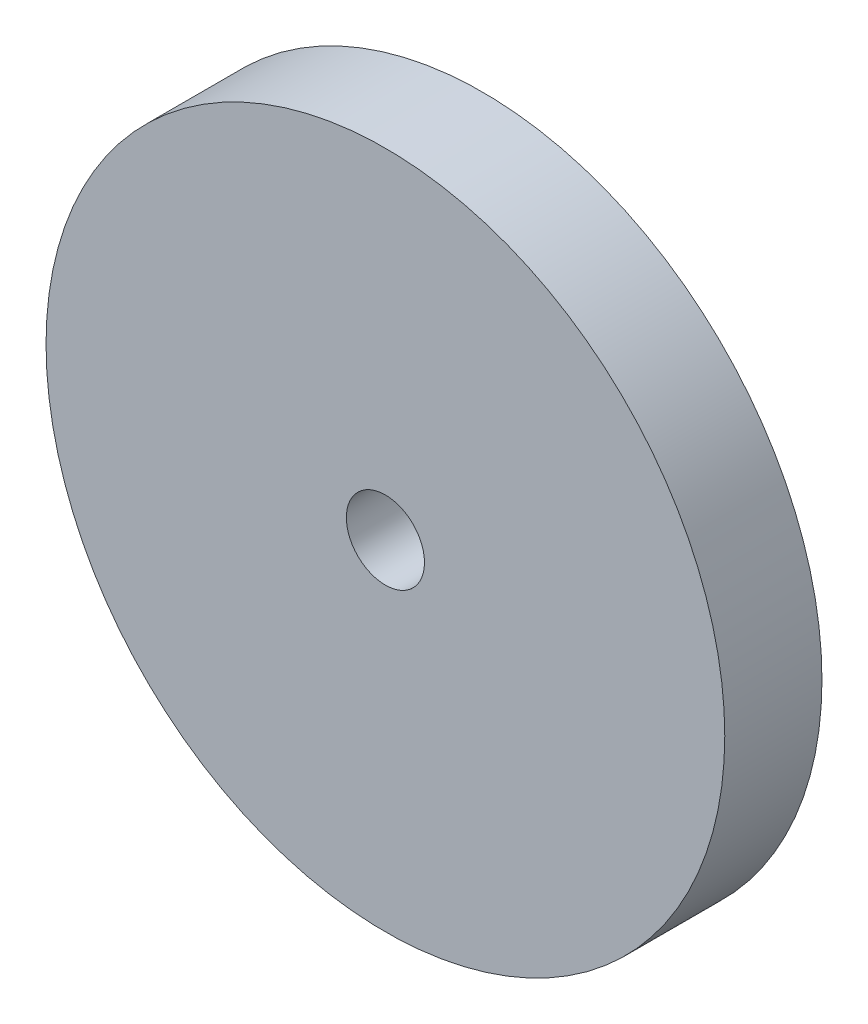
from build123d import *

# Parameters (mm, degrees)
SKETCH1_R           = 22.175
SKETCH1_R_2         = 2.5527
BOSS_EXTRUDE1_DEPTH = 6.35


with BuildPart() as part:
    # Sketch1 → Boss-Extrude1 (new body)
    with BuildSketch(Plane.XY):
        Circle(SKETCH1_R)
        Circle(SKETCH1_R_2, mode=Mode.SUBTRACT)
    extrude(amount=BOSS_EXTRUDE1_DEPTH)


solid = part.part
